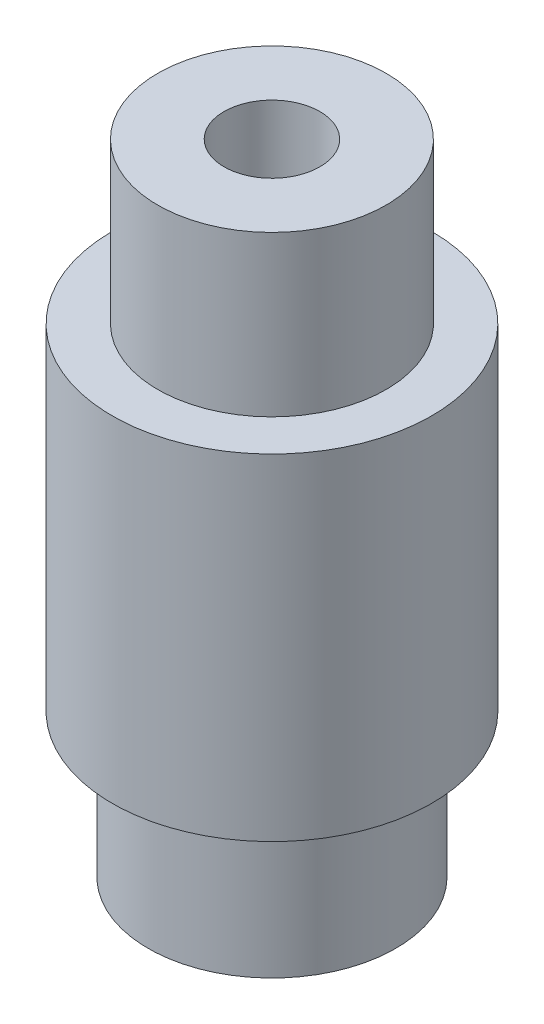
from build123d import *


with BuildPart() as part:
    # Эскиз1 → Повернуть1 (revolve)
    with BuildSketch(Plane.XY):
        Polygon((-3, 0), (-7.75, 0), (-7.75, 8.987874114), (-10, 8.987874114), (-10, 30), (-7.15, 30), (-7.15, 40), (-3, 40), align=None)
    revolve(axis=Axis((0, -8.728436619, 0), (0, 1, 0)))


solid = part.part
